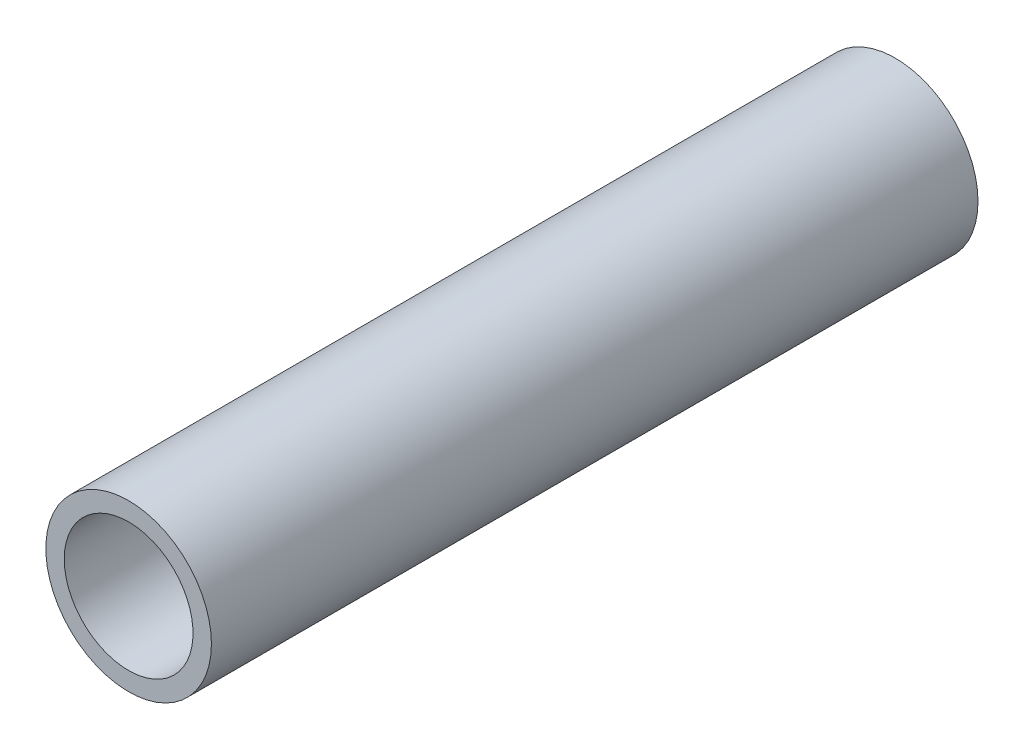
from build123d import *

# Parameters (mm, degrees)
SKETCH1_R           = 13.716
BOSS_EXTRUDE1_DEPTH = 127
SKETCH2_R           = 10.668
CUT_EXTRUDE1_DEPTH  = 127
SCALE1_SCALE        = 0.735294118
SCALE2_SCALE        = 0.892857143
SCALE3_SCALE        = 1.056338028


with BuildPart() as part:
    # Sketch1 → Boss-Extrude1 (new body)
    with BuildSketch(Plane.XY):
        with Locations((-7.319167791, 4.997022186)):
            Circle(SKETCH1_R)
    extrude(amount=BOSS_EXTRUDE1_DEPTH)

    # Sketch2 → Cut-Extrude1 (cut)
    with BuildSketch(Plane(origin=(0, 0, 0), x_dir=(-1, 0, 0), z_dir=(0, 0, -1))):
        with Locations((7.319167791, 4.997022186)):
            Circle(SKETCH2_R)
    extrude(amount=-CUT_EXTRUDE1_DEPTH, mode=Mode.SUBTRACT)


with BuildPart() as part_1:
    # Scale1: scaled about (-7.319167791, 4.997022186, 63.5)
    add(part.part.scale(SCALE1_SCALE).moved(Location((-1.937426768, 1.322741167, 16.808823529))))


with BuildPart() as part_2:
    # Scale2: scaled about (-7.319167791, 4.997022186, 63.5)
    add(part_1.part.scale(SCALE2_SCALE).moved(Location((-0.784196549, 0.535395234, 6.803571429))))


with BuildPart() as part_3:
    # Scale3: scaled about (-7.319167791, 4.997022186, 63.5)
    add(part_2.part.scale(SCALE3_SCALE).moved(Location((0.412347481, -0.281522377, -3.577464789))))


solid = part_3.part
